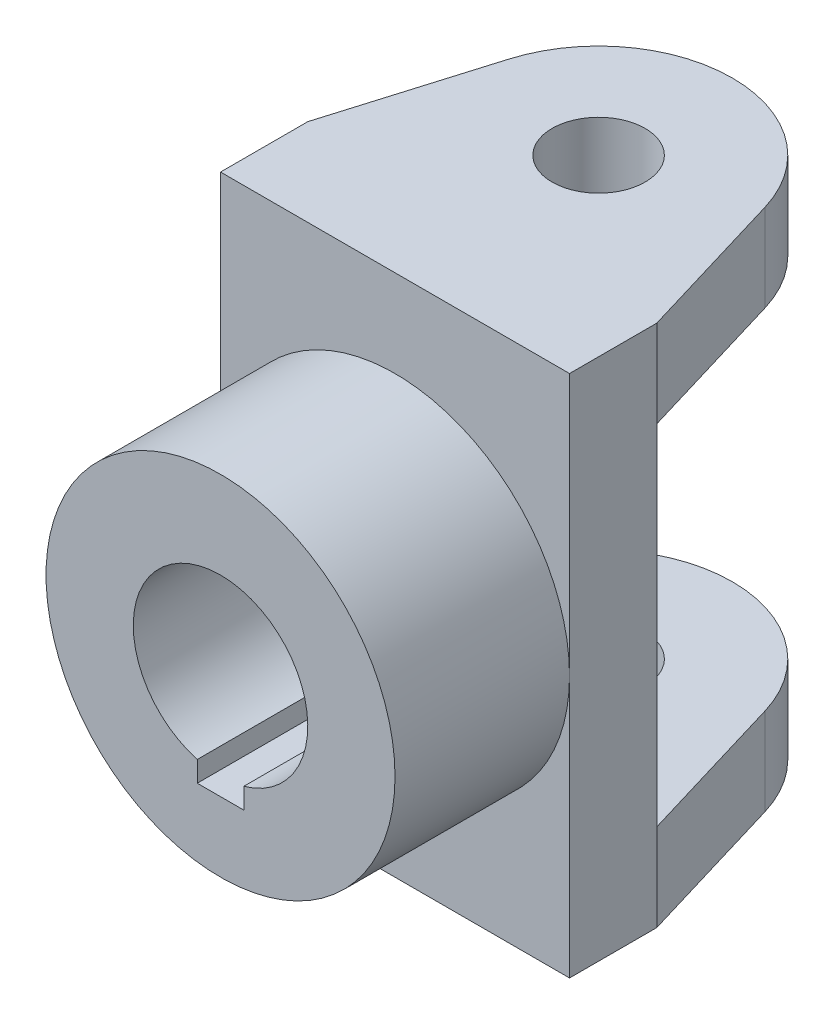
from build123d import *

# Parameters (mm, degrees)
SKETCH1_W           = 60
SKETCH1_H           = 90
BOSS_EXTRUDE1_DEPTH = 15
SKETCH2_R           = 30
BOSS_EXTRUDE2_DEPTH = 30
SKETCH3_R           = 8
BOSS_EXTRUDE3_DEPTH = 15


with BuildPart() as part:
    # Sketch1 → Boss-Extrude1 (new body)
    with BuildSketch(Plane.XY):
        Rectangle(SKETCH1_W, SKETCH1_H)
    extrude(amount=BOSS_EXTRUDE1_DEPTH)

    # Sketch2 → Boss-Extrude2 (add)
    with BuildSketch(Plane.XY.offset(15)):
        Circle(SKETCH2_R)
        with BuildLine():
            Line((-4, -14.456832295), (-4, -18))
            Line((-4, -18), (4, -18))
            Line((4, -18), (4, -14.456832295))
            ThreePointArc((4, -14.456832295), (0, 15), (-4, -14.456832295))
        make_face(mode=Mode.SUBTRACT)
    extrude(amount=BOSS_EXTRUDE2_DEPTH)

    # Sketch3 → Boss-Extrude3 (add)
    with BuildSketch(Plane(origin=(0, 45, 0), x_dir=(1, 0, 0), z_dir=(0, 1, 0))):
        with BuildLine():
            Line((-30, 0), (30, 0))
            Line((30, 0), (22.03289839, 26.599347585))
            ThreePointArc((22.03289839, 26.599347585), (0, 43), (-22.03289839, 26.599347585))
            Line((-22.03289839, 26.599347585), (-30, 0))
        make_face()
        with Locations((0, 20)):
            Circle(SKETCH3_R, mode=Mode.SUBTRACT)
    boss_extrude3 = extrude(amount=-BOSS_EXTRUDE3_DEPTH)

    # Mirror1: Boss-Extrude3 across plane
    add(boss_extrude3.mirror(Plane.ZX))


solid = part.part
